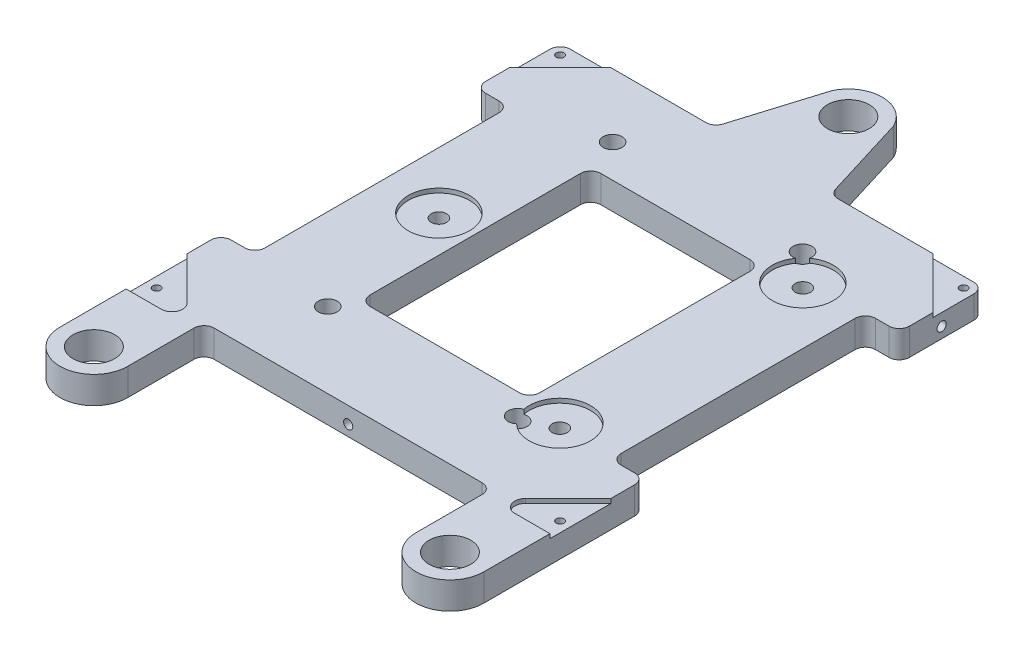
from build123d import *

# Parameters (mm, degrees)
BOSS_EXTRUDE1_DEPTH                            = 8
SKETCH8_W                                      = 50
SKETCH8_H                                      = 68
SKETCH8_W_2                                    = 10
SKETCH8_H_2                                    = 75
CUT_EXTRUDE2_DEPTH                             = 9
F_9_16_12_TAPPED_HOLE1_D                       = 12.30376
FILLET1_R                                      = 3
M4_CLEARANCE_HOLE1_D                           = 4.5
SKETCH7_R                                      = 9.0297
CUT_EXTRUDE1_DEPTH                             = 1.27
F_4_40_TAPPED_HOLE1_D                          = 2.2606
CUT_EXTRUDE3_DEPTH                             = 1.27
FILLET2_R                                      = 3.175
FILLET2_OF_MIRROR1_R                           = 3.175
CBORE_FOR_4_SOCKET_HEAD_CAP_SCREW1_D           = 3.2639
CBORE_FOR_4_SOCKET_HEAD_CAP_SCREW1_CBORE_D     = 5.55752
CBORE_FOR_4_SOCKET_HEAD_CAP_SCREW1_CBORE_DEPTH = 5.999999938
F_6_32_TAPPED_HOLE2_D                          = 2.7051
F_6_32_TAPPED_HOLE2_DEPTH                      = 10.97
F_6_32_TAPPED_HOLE2_TIP                        = 0.81269403


with BuildPart() as part:
    # Sketch1 → Boss-Extrude1 (new body)
    with BuildSketch(Plane(origin=(0, 0, 0), x_dir=(1, 0, 0), z_dir=(0, 1, 0))):
        with BuildLine():
            Line((62.5, -85), (62.5, 62.5))
            Line((62.5, 62.5), (17.267202684, 62.5))
            Line((17.267202684, 62.5), (9.08736201, 89.173709584))
            ThreePointArc((9.08736201, 89.173709584), (0, 95), (-9.08736201, 89.173709584))
            Line((-9.08736201, 89.173709584), (-17.267202684, 62.5))
            Line((-17.267202684, 62.5), (-62.5, 62.5))
            Line((-62.5, 62.5), (-62.5, -85))
            ThreePointArc((-62.5, -85), (-52.5, -95), (-42.5, -85))
            Line((-42.5, -85), (-42.5, -62.5))
            Line((-42.5, -62.5), (42.5, -62.5))
            Line((42.5, -62.5), (42.5, -85))
            ThreePointArc((42.5, -85), (52.5, -95), (62.5, -85))
        make_face()
    extrude(amount=-BOSS_EXTRUDE1_DEPTH)

    # Sketch8 → Cut-Extrude2 (cut, through all)
    with BuildSketch(Plane(origin=(0, 0, 0), x_dir=(1, 0, 0), z_dir=(0, 1, 0))):
        Rectangle(SKETCH8_W, SKETCH8_H)
        with Locations((-57.5, 0)):
            Rectangle(SKETCH8_W_2, SKETCH8_H_2)
        with Locations((57.5, 0)):
            Rectangle(SKETCH8_W_2, SKETCH8_H_2)
    extrude(amount=-CUT_EXTRUDE2_DEPTH, mode=Mode.SUBTRACT)

    # 9/16-12 Tapped Hole1 (through all)
    with Locations(Plane(origin=(-52.5, 0, 85), x_dir=(0, 0, 1), z_dir=(0, 1, 0))):
        with Locations((0, 0), (-170, 52.5), (0, 105)):
            Hole(F_9_16_12_TAPPED_HOLE1_D / 2)

    # Fillet1
    fillet1_edges = [part.edges().sort_by_distance(p)[0] for p in [
        (17.267202684, -4, -62.5),
        (62.5, -4, -62.5),
        (42.5, -4, 62.5),
        (-42.5, -4, 62.5),
        (-62.5, -4, -62.5),
        (-17.267202684, -4, -62.5),
        (-25, -4, 34),
        (-25, -4, -34),
        (25, -4, -34),
        (25, -4, 34),
        (-62.5, -4, 37.5),
        (-62.5, -4, -37.5),
        (-52.5, -4, -37.5),
        (-52.5, -4, 37.5),
        (62.5, -4, -37.5),
        (62.5, -4, 37.5),
        (52.5, -4, 37.5),
        (52.5, -4, -37.5),
    ]]
    fillet(fillet1_edges, radius=FILLET1_R)

    # M4 Clearance Hole1 (through all)
    with Locations(Plane(origin=(0, 0, 0), x_dir=(1, 0, 0), z_dir=(0, 1, 0))):
        with Locations((-35.745, 0), (35.745, -35.829), (35.745, 35.829)):
            Hole(M4_CLEARANCE_HOLE1_D / 2)

    # Sketch7 → Cut-Extrude1 (cut)
    with BuildSketch(Plane(origin=(0, 0, 0), x_dir=(1, 0, 0), z_dir=(0, 1, 0))):
        with Locations(Location((-35.745, 0, 0), (0, 0, 270))):  # turned: the seam where the file's is
            Circle(SKETCH7_R)
        with Locations(Location((35.745, 35.829, 0), (0, 0, 270))):  # turned: the seam where the file's is
            Circle(SKETCH7_R)
        with Locations(Location((35.745, -35.829, 0), (0, 0, 270))):  # turned: the seam where the file's is
            Circle(SKETCH7_R)
    extrude(amount=-CUT_EXTRUDE1_DEPTH, mode=Mode.SUBTRACT)

    # #4-40 Tapped Hole1 (through all)
    with Locations(Plane(origin=(0, 0, 0), x_dir=(1, 0, 0), z_dir=(0, 1, 0))):
        with Locations((-59.5, 59.5), (59.5, 59.5), (59.5, -59.5), (-59.5, -59.5)):
            Hole(F_4_40_TAPPED_HOLE1_D / 2)

    # Sketch11 → Cut-Extrude3 (cut)
    with BuildSketch(Plane(origin=(0, 0, 0), x_dir=(1, 0, 0), z_dir=(0, 1, 0))):
        with BuildLine():
            Line((-62.5, 47.5), (-47.5, 62.5))
            Line((-47.5, 62.5), (-59.5, 62.5))
            ThreePointArc((-59.5, 62.5), (-61.621320344, 61.621320344), (-62.5, 59.5))
            Line((-62.5, 59.5), (-62.5, 47.5))
        make_face()
        Polygon((-62.5, -47.5), (-44.5, -65.5), (-62.5, -65.5), align=None)
    cut_extrude3 = extrude(amount=-CUT_EXTRUDE3_DEPTH, mode=Mode.SUBTRACT)

    # Fillet2
    fillet2_edges = [part.edges().sort_by_distance(p)[0] for p in [
        (-44.5, -0.635, 65.5),
    ]]
    fillet(fillet2_edges, radius=FILLET2_R)

    # Mirror1: Cut-Extrude3 across plane
    add(cut_extrude3.mirror(Plane(origin=(0, 0, 0), x_dir=(0, 0, 1), z_dir=(1, 0, 0))), mode=Mode.SUBTRACT)

    # Fillet2 of Mirror1
    fillet2_of_mirror1_edges = [part.edges().sort_by_distance(p)[0] for p in [
        (44.5, -0.635, 65.5),
    ]]
    fillet(fillet2_of_mirror1_edges, radius=FILLET2_OF_MIRROR1_R)

    # Sketch13 → #6-32 Tapped Hole1 (revolve, cut)
    with BuildSketch(Plane(origin=(62.5, -4.825, -50.025), x_dir=(0, 0, -1), z_dir=(0, 1, 0))):
        Polygon((0, 0), (0, 11.78269403), (1.35255, 10.97), (1.35255, 0), align=None)
    f_6_32_tapped_hole1 = revolve(axis=Axis((68.85, -4.825, -50.025), (-1, 0, 0)), mode=Mode.SUBTRACT)

    # Mirror2: #6-32 Tapped Hole1 across plane
    add(f_6_32_tapped_hole1.mirror(Plane(origin=(0, 0, 0), x_dir=(0, 0, 1), z_dir=(1, 0, 0))), mode=Mode.SUBTRACT)

    # CBORE for #4 Socket Head Cap Screw1 (through all)
    with Locations(Plane(origin=(0, 0, 0), x_dir=(1, 0, 0), z_dir=(0, 1, 0))):
        with Locations((-28.276, 43.752), (27.724, 43.752), (27.724, -40.248), (-28.276, -40.248)):
            CounterBoreHole(CBORE_FOR_4_SOCKET_HEAD_CAP_SCREW1_D / 2, CBORE_FOR_4_SOCKET_HEAD_CAP_SCREW1_CBORE_D / 2, CBORE_FOR_4_SOCKET_HEAD_CAP_SCREW1_CBORE_DEPTH)

    # #6-32 Tapped Hole2
    with Locations(Plane.XY.offset(62.5)):
        with Locations((0, -4.825)):
            Hole(F_6_32_TAPPED_HOLE2_D / 2, depth=F_6_32_TAPPED_HOLE2_DEPTH)
            with Locations((0, 0, -(F_6_32_TAPPED_HOLE2_DEPTH + F_6_32_TAPPED_HOLE2_TIP / 2))):  # 118° drill point
                Cone(0, F_6_32_TAPPED_HOLE2_D / 2, F_6_32_TAPPED_HOLE2_TIP, mode=Mode.SUBTRACT)


solid = part.part
